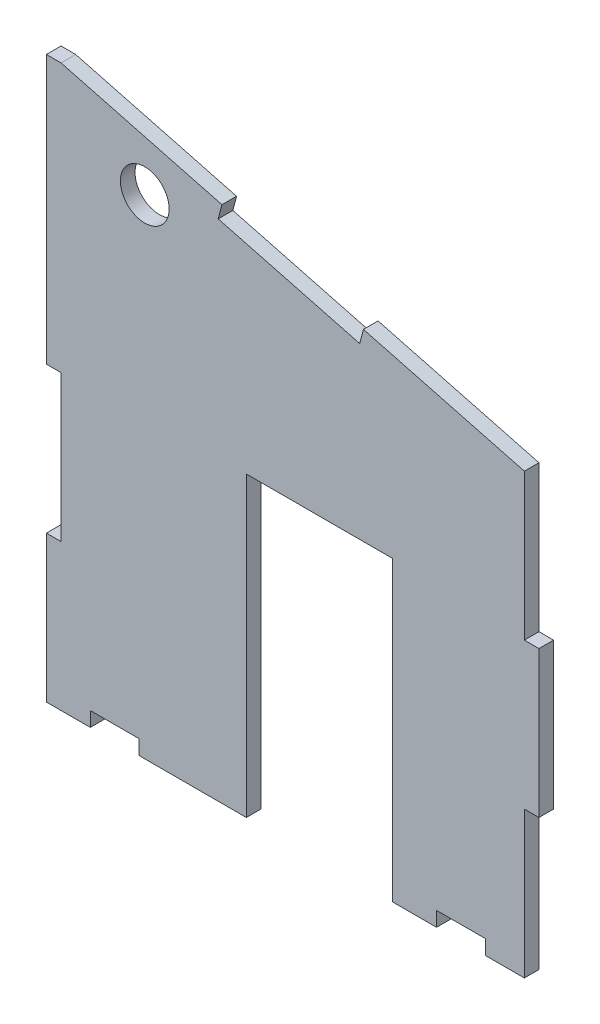
from build123d import *

# Parameters (mm, degrees)
MODEL_R             = 5
BOSS_EXTRUDE1_DEPTH = 3


with BuildPart() as part:
    # Model → Boss-Extrude1 (new body)
    with BuildSketch(Plane.XY):
        Polygon((352.69017886, 199.123752973), (352.69017886, 169.123752973), (349.69017886, 169.123752973), (349.69017886, 139.123752973), (341.69017886, 139.123752973), (341.69017886, 142.123752973), (331.69017886, 142.123752973), (331.69017886, 139.123752973), (322.69017886, 139.123752973), (322.69017886, 200.123752973), (292.69017886, 200.123752973), (292.69017886, 139.123752973), (270.69017886, 139.123752973), (270.69017886, 142.123752973), (260.69017886, 142.123752973), (260.69017886, 139.123752973), (251.69017886, 139.123752973), (251.69017886, 169.123752973), (254.69017886, 169.123752973), (254.69017886, 199.123752973), (251.69017886, 199.123752973), (251.69017886, 254.123752973), (254.69017886, 254.123752973), (287.684060801, 245.441152462), (286.920580903, 242.539928851), (315.932817021, 234.905129872), (316.696296919, 237.806353484), (349.69017886, 229.123752973), (349.69017886, 199.123752973), align=None)
        with Locations((271.859853833, 239.264952873)):
            Circle(MODEL_R, mode=Mode.SUBTRACT)
    extrude(amount=BOSS_EXTRUDE1_DEPTH)


solid = part.part
